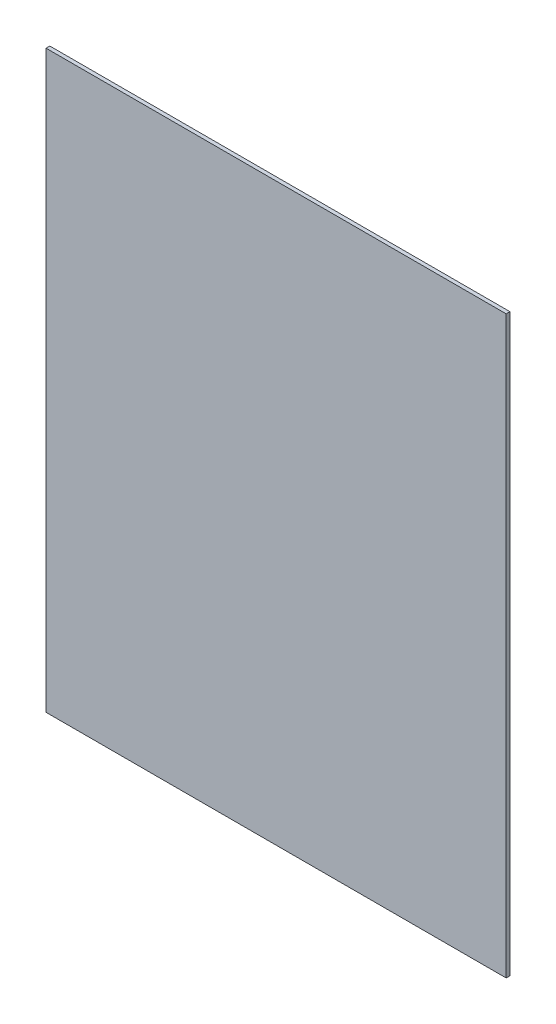
from build123d import *

# Parameters (mm, degrees)
SKETCH1_W           = 244
SKETCH1_H           = 305
BOSS_EXTRUDE1_DEPTH = 2


with BuildPart() as part:
    # Sketch1 → Boss-Extrude1 (new body)
    with BuildSketch(Plane.XY):
        Rectangle(SKETCH1_W, SKETCH1_H)
    extrude(amount=BOSS_EXTRUDE1_DEPTH)


solid = part.part
